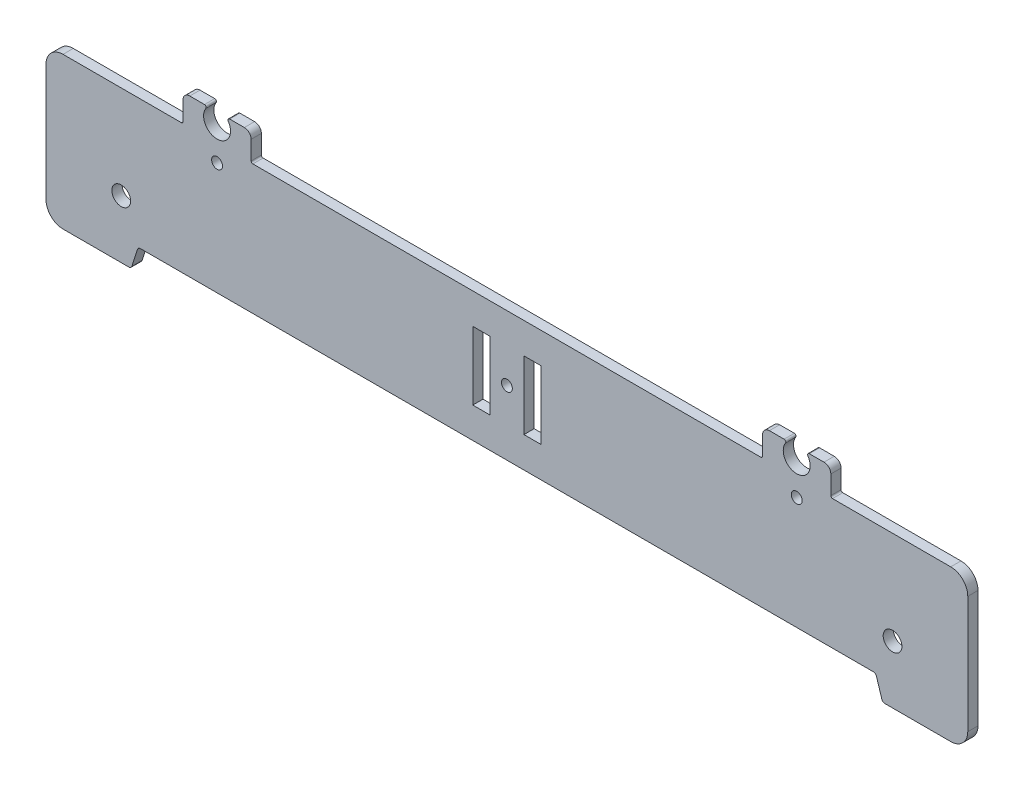
from build123d import *

# Parameters (mm, degrees)
MODEL_R                 = 1.6
MODEL_R_2               = 2.75
SALIENTE_EXTRUIR1_DEPTH = 3


with BuildPart() as part:
    # Model → Saliente-Extruir1 (new body)
    with BuildSketch(Plane.XY):
        with BuildLine():
            Line((154.018604018, 58.836275918), (79.516105518, 58.836274418))
            ThreePointArc((79.516105518, 58.836274418), (79.162552127, 58.982721028), (79.016105518, 59.336274418))
            Line((79.016105518, 59.336274418), (79.016105518, 64.834297418))
            ThreePointArc((79.016105518, 64.834297418), (78.43031908, 66.248510981), (77.016105518, 66.834297418))
            Line((77.016105518, 66.834297418), (72.69995292, 66.834297418))
            ThreePointArc((72.69995292, 66.834297418), (72.258226513, 66.568557489), (72.286037482, 66.053808542))
            ThreePointArc((72.286037482, 66.053808542), (69.016105518, 59.887946419), (65.746173553, 66.053808542))
            ThreePointArc((65.746173553, 66.053808542), (65.773984522, 66.56855749), (65.332258115, 66.834297418))
            Line((65.332258115, 66.834297418), (61.016105518, 66.834297418))
            ThreePointArc((61.016105518, 66.834297418), (59.601891956, 66.248510981), (59.016105518, 64.834297418))
            Line((59.016105518, 64.834297418), (59.016105518, 59.336277418))
            ThreePointArc((59.016105518, 59.336277418), (58.869658908, 58.982724028), (58.516105518, 58.836277418))
            Line((58.516105518, 58.836277418), (28.843601518, 58.836277418))
            Line((28.843601518, 58.836277418), (23.843601518, 58.836277418))
            ThreePointArc((23.843601518, 58.836277418), (20.308067612, 57.371811324), (18.843601518, 53.836277418))
            Line((18.843601518, 53.836277418), (18.843601518, 19.448682418))
            ThreePointArc((18.843601518, 19.448682418), (20.308068445, 15.91314768), (23.843603874, 14.448682418))
            Line((23.843603874, 14.448682418), (43.108834237, 14.448682418))
            ThreePointArc((43.108834237, 14.448682418), (43.70094804, 14.642828062), (44.063149212, 15.149879929))
            Line((44.063149212, 15.149879929), (45.624053822, 20.135094908))
            ThreePointArc((45.624053822, 20.135094908), (45.986254995, 20.642146775), (46.578368798, 20.836292418))
            Line((46.578368798, 20.836292418), (154.018604018, 20.833862066))
            Line((154.018604018, 20.833862066), (261.458839238, 20.836292418))
            ThreePointArc((261.458839238, 20.836292418), (262.050953041, 20.642146775), (262.413154213, 20.135094908))
            Line((262.413154213, 20.135094908), (263.974058823, 15.149879929))
            ThreePointArc((263.974058823, 15.149879929), (264.336259996, 14.642828062), (264.928373799, 14.448682418))
            Line((264.928373799, 14.448682418), (284.193604162, 14.448682418))
            ThreePointArc((284.193604162, 14.448682418), (287.729139591, 15.91314768), (289.193606518, 19.448682418))
            Line((289.193606518, 19.448682418), (289.193606518, 53.836277418))
            ThreePointArc((289.193606518, 53.836277418), (287.729140424, 57.371811324), (284.193606518, 58.836277418))
            Line((284.193606518, 58.836277418), (279.193606518, 58.836277418))
            Line((279.193606518, 58.836277418), (249.521102518, 58.836277418))
            ThreePointArc((249.521102518, 58.836277418), (249.167549127, 58.982724028), (249.021102518, 59.336277418))
            Line((249.021102518, 59.336277418), (249.021102518, 64.834297418))
            ThreePointArc((249.021102518, 64.834297418), (248.43531608, 66.248510981), (247.021102518, 66.834297418))
            Line((247.021102518, 66.834297418), (242.704949921, 66.834297418))
            ThreePointArc((242.704949921, 66.834297418), (242.263223513, 66.56855749), (242.291034482, 66.053808542))
            ThreePointArc((242.291034482, 66.053808542), (239.021102518, 59.887946419), (235.751170554, 66.053808542))
            ThreePointArc((235.751170554, 66.053808542), (235.778981523, 66.568557489), (235.337255116, 66.834297418))
            Line((235.337255116, 66.834297418), (231.021102518, 66.834297418))
            ThreePointArc((231.021102518, 66.834297418), (229.606888956, 66.248510981), (229.021102518, 64.834297418))
            Line((229.021102518, 64.834297418), (229.021102518, 59.336274418))
            ThreePointArc((229.021102518, 59.336274418), (228.874655908, 58.982721028), (228.521102518, 58.836274418))
            Line((228.521102518, 58.836274418), (154.018604018, 58.836275918))
        make_face()
        with Locations((69.016105518, 53.837946418)):
            Circle(MODEL_R, mode=Mode.SUBTRACT)
        with Locations((154.018604018, 39.835068992)):
            Circle(MODEL_R, mode=Mode.SUBTRACT)
        with Locations((239.021102518, 53.837946418)):
            Circle(MODEL_R, mode=Mode.SUBTRACT)
        with Locations((40.904504018, 31.448682418)):
            Circle(MODEL_R_2, mode=Mode.SUBTRACT)
        with Locations((267.132704018, 31.448682418)):
            Circle(MODEL_R_2, mode=Mode.SUBTRACT)
        Polygon((144.018604018, 39.835068992), (144.018604018, 49.835068992), (149.018604018, 49.835068992), (149.018604018, 29.835068992), (144.018604018, 29.835068992), align=None, mode=Mode.SUBTRACT)
        Polygon((164.018604018, 39.835068992), (164.018604018, 49.835068992), (159.018604018, 49.835068992), (159.018604018, 29.835068992), (164.018604018, 29.835068992), align=None, mode=Mode.SUBTRACT)
    extrude(amount=SALIENTE_EXTRUIR1_DEPTH)


solid = part.part
